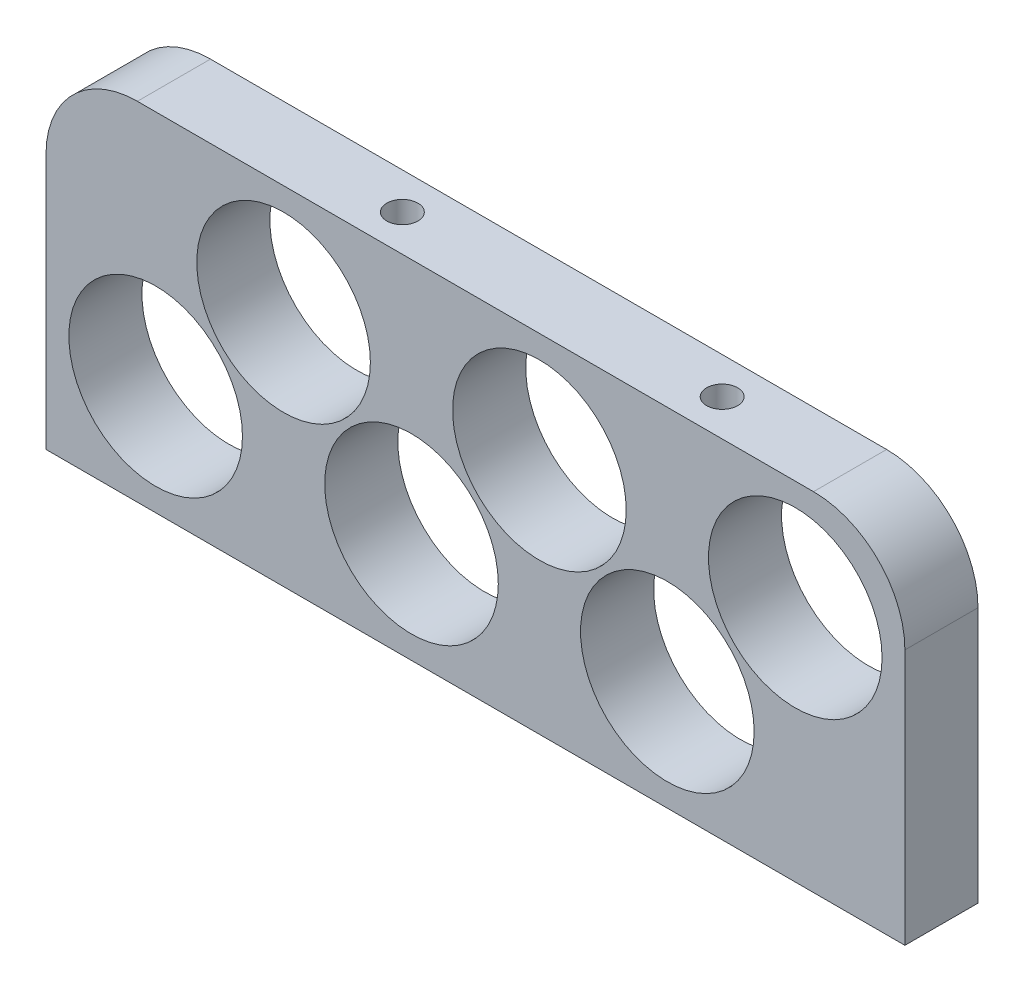
from build123d import *

# Parameters (mm, degrees)
SKETCH2_W           = 94
SKETCH2_H           = 38
SKETCH2_R           = 9.5
BOSS_EXTRUDE1_DEPTH = 8
FILLET1_R           = 10
SKETCH3_R           = 1.7
CUT_EXTRUDE1_DEPTH  = 5


with BuildPart() as part:
    # Sketch2 → Boss-Extrude1 (new body)
    with BuildSketch(Plane.XY):
        with Locations((-151.821569614, 20.991771931)):
            Rectangle(SKETCH2_W, SKETCH2_H)
        with Locations((-186.821569614, 13.991771931)):
            Circle(SKETCH2_R, mode=Mode.SUBTRACT)
        with Locations((-158.821569614, 13.991771931)):
            Circle(SKETCH2_R, mode=Mode.SUBTRACT)
        with Locations((-130.821569614, 13.991771931)):
            Circle(SKETCH2_R, mode=Mode.SUBTRACT)
        with Locations((-144.821569614, 27.991771931)):
            Circle(SKETCH2_R, mode=Mode.SUBTRACT)
        with Locations((-116.821569614, 27.991771931)):
            Circle(SKETCH2_R, mode=Mode.SUBTRACT)
        with Locations((-172.821569614, 27.991771931)):
            Circle(SKETCH2_R, mode=Mode.SUBTRACT)
    extrude(amount=BOSS_EXTRUDE1_DEPTH)

    # Fillet1
    fillet1_edges = [part.edges().sort_by_distance(p)[0] for p in [
        (-198.821569614, 39.991771931, 4),
        (-104.821569614, 39.991771931, 4),
    ]]
    fillet(fillet1_edges, radius=FILLET1_R)

    # Sketch3 → Cut-Extrude1 (cut)
    with BuildSketch(Plane(origin=(0, 39.991771931, 0), x_dir=(1, 0, 0), z_dir=(0, 1, 0))):
        with Locations((-163.821569614, -4)):
            Circle(SKETCH3_R)
        with Locations((-128.821569614, -4)):
            Circle(SKETCH3_R)
    extrude(amount=-CUT_EXTRUDE1_DEPTH, mode=Mode.SUBTRACT)


solid = part.part
